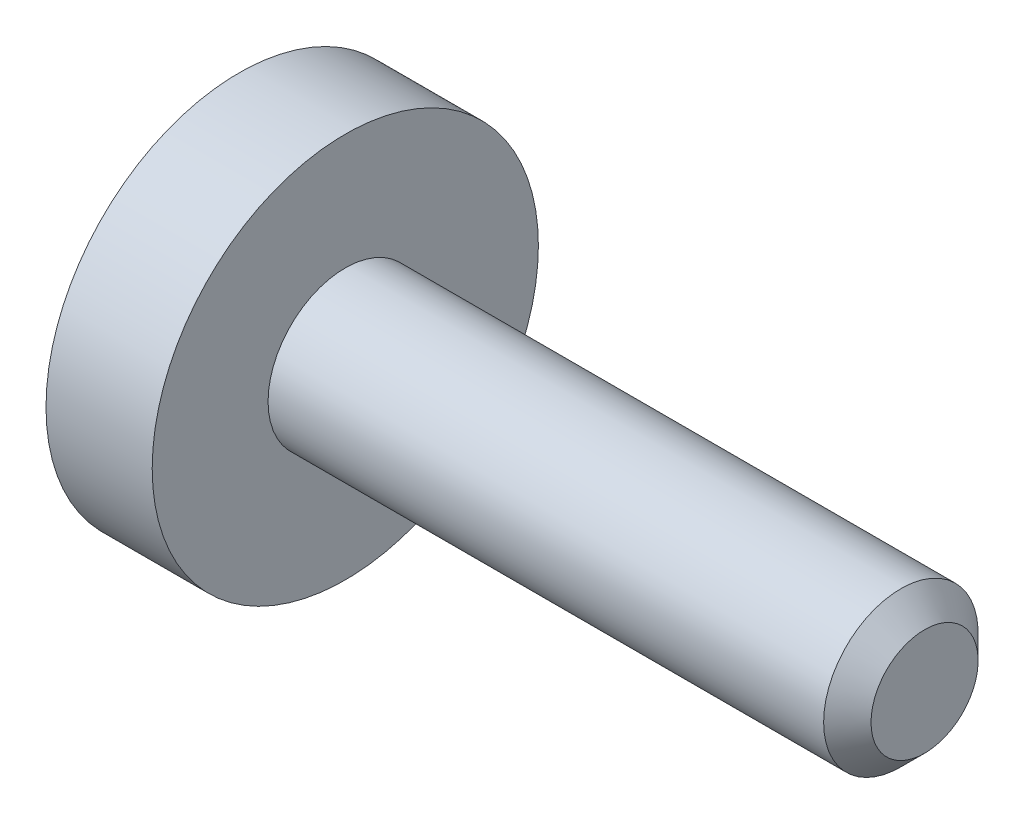
from build123d import *

# Parameters (mm, degrees)
CUT_EXTRUDE1_DEPTH = 1.2


with BuildPart() as part:
    # Sketch1 → Revolve1 (revolve)
    with BuildSketch(Plane.XY):
        Polygon((-1.1, 0), (-1.1, 2), (0, 2), (0, 0.8), (5.7545, 0.8), (6, 0.5545), (6, 0), align=None)
    revolve(axis=Axis((6, 0, 0), (-1, 0, 0)))

    # Sketch2 → Cut-Extrude1 (cut)
    with BuildSketch(Plane(origin=(-1.1, 0, 0), x_dir=(0, 0, -1), z_dir=(1, 0, 0))):
        Polygon((-0.65, -0.375277675), (0, -0.75055535), (0.65, -0.375277675), (0.65, 0.375277675), (0, 0.75055535), (-0.65, 0.375277675), align=None)
    extrude(amount=CUT_EXTRUDE1_DEPTH, mode=Mode.SUBTRACT)


solid = part.part
